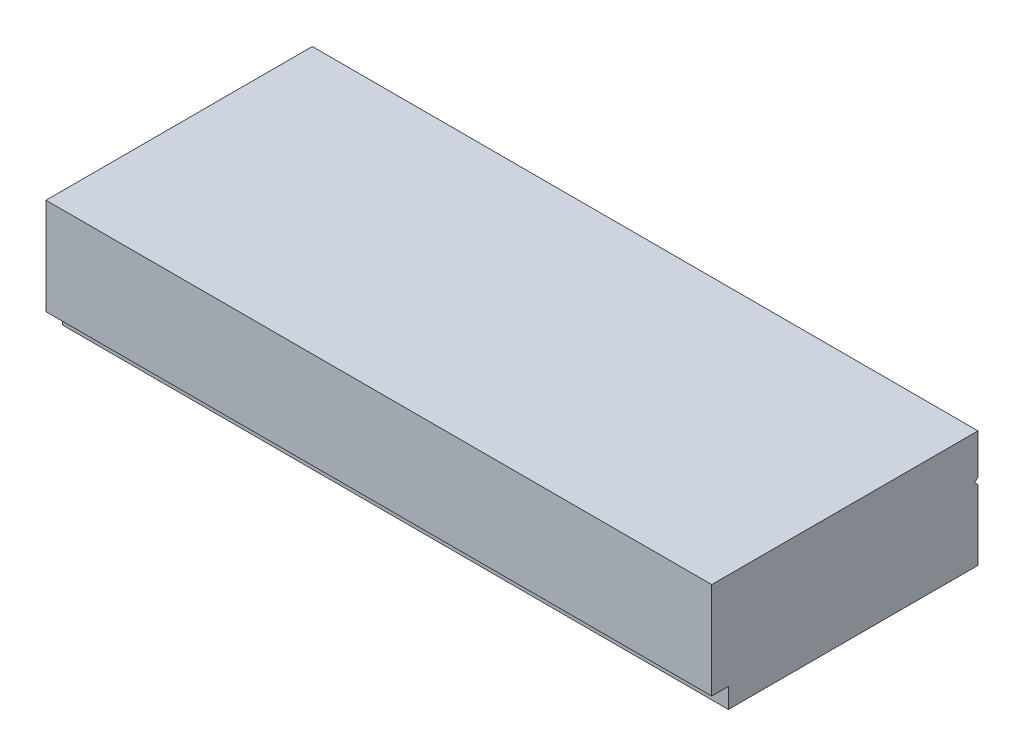
from build123d import *

# Parameters (mm, degrees)
SKETCH1_W           = 200
SKETCH1_H           = 80
BOSS_EXTRUDE1_DEPTH = 35
SKETCH2_W           = 5
SKETCH2_H           = 6
CUT_EXTRUDE1_DEPTH  = 201
CUT_EXTRUDE5_DEPTH  = 201


with BuildPart() as part:
    # Sketch1 → Boss-Extrude1 (new body)
    with BuildSketch(Plane(origin=(0, 0, 0), x_dir=(1, 0, 0), z_dir=(0, 1, 0))):
        Rectangle(SKETCH1_W, SKETCH1_H)
    extrude(amount=BOSS_EXTRUDE1_DEPTH)

    # Sketch2 → Cut-Extrude1 (cut, through all)
    with BuildSketch(Plane.ZY.offset(100)):
        with Locations((37.5, 3)):
            Rectangle(SKETCH2_W, SKETCH2_H)
    extrude(amount=-CUT_EXTRUDE1_DEPTH, mode=Mode.SUBTRACT)

    # Sketch6 → Cut-Extrude5 (cut, through all)
    with BuildSketch(Plane(origin=(100, 0, 0), x_dir=(0, 0, -1), z_dir=(1, 0, 0))):
        Polygon((40, 22), (40, 23), (39, 22), (40, 21), align=None)
    extrude(amount=-CUT_EXTRUDE5_DEPTH, mode=Mode.SUBTRACT)


solid = part.part
